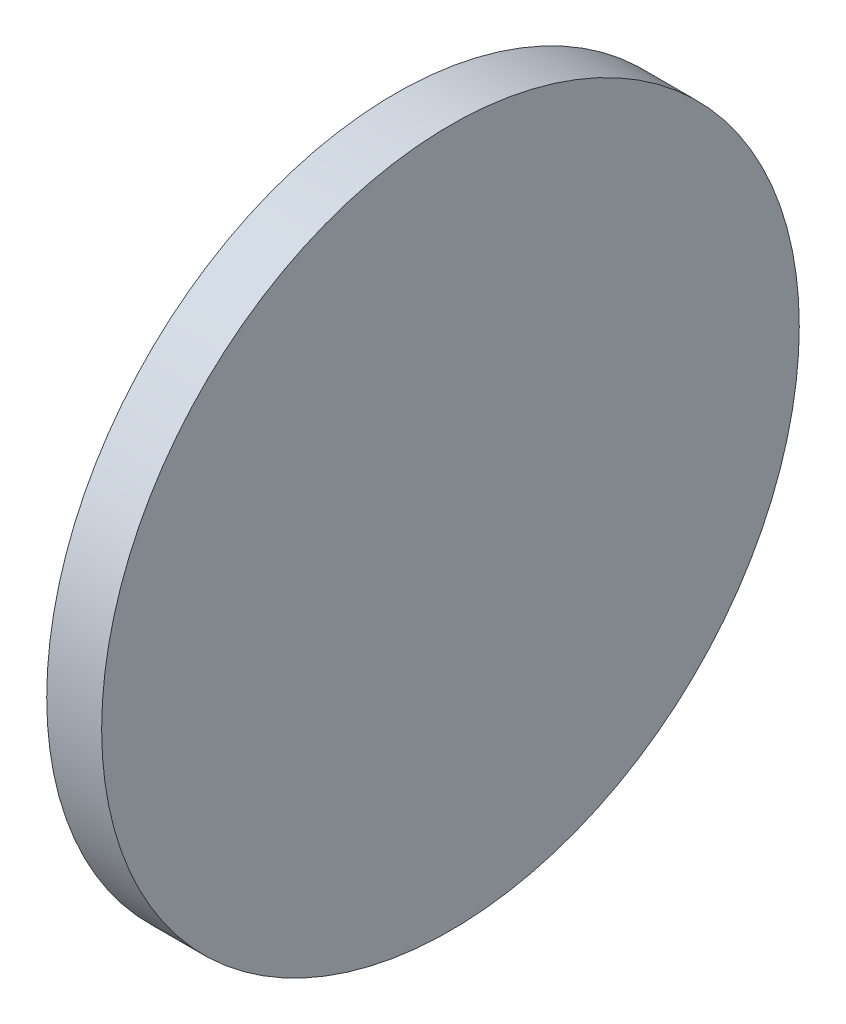
from build123d import *

# Parameters (mm, degrees)
SKETCH_1_W = 2
SKETCH_1_H = 12.7


with BuildPart() as part:
    # 草图1 → 旋转2 (revolve)
    with BuildSketch(Plane.XY, mode=Mode.PRIVATE) as revolve_2_sk:
        with Locations((1, 6.35)):
            Rectangle(SKETCH_1_W, SKETCH_1_H)
    revolve(revolve_2_sk.sketch.rotate(Axis((0, 0, 0), (1, 0, 0)), 90), axis=Axis((0, 0, 0), (1, 0, 0)))  # turned: the seam where the file's is


solid = part.part
